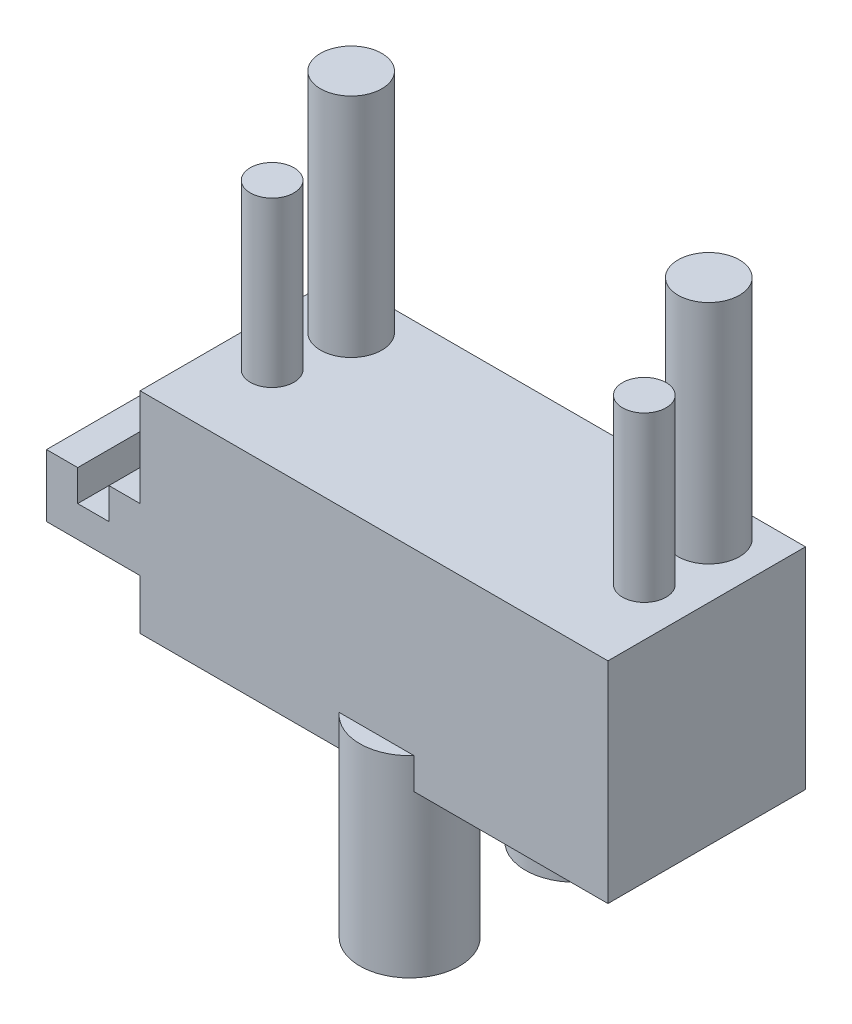
from build123d import *

# Parameters (mm, degrees)
SKETCH1_W                = 22.5
SKETCH1_H                = 7
BOSS_EXTRUDE1_DEPTH      = 1.5
SKETCH2_R                = 1.475
BOSS_EXTRUDE2_DEPTH      = 13.5
SKETCH3_R                = 1.05
BOSS_EXTRUDE3_DEPTH      = 10.5
SKETCH4_W                = 22.5
SKETCH4_H                = 2.5
SKETCH4_H_2              = 7
BOSS_EXTRUDE4_DEPTH      = 6
BOSS_EXTRUDE4_DEPTH_BACK = 1.5
SKETCH8_W                = 22.5
SKETCH8_H                = 9.5
BOSS_EXTRUDE7_DEPTH      = 2.61
SKETCH9_R                = 2.4
BOSS_EXTRUDE8_DEPTH      = 7.76
BOSS_EXTRUDE8_DEPTH_BACK = 1.5
SKETCH15_W               = 9.5
SKETCH15_H               = 3
BOSS_EXTRUDE11_DEPTH     = 4.5
SKETCH16_W               = 1.5
SKETCH16_H               = 9.5
CUT_EXTRUDE3_DEPTH       = 1.5


with BuildPart() as part:
    # Sketch1 → Boss-Extrude1 (new body)
    with BuildSketch(Plane(origin=(0, 0, 0), x_dir=(1, 0, 0), z_dir=(0, 1, 0))):
        with Locations((-28.93578967, -21.079480712)):
            Rectangle(SKETCH1_W, SKETCH1_H)
    extrude(amount=BOSS_EXTRUDE1_DEPTH)

    # Sketch2 → Boss-Extrude2 (add)
    with BuildSketch(Plane(origin=(0, 1.5, 0), x_dir=(1, 0, 0), z_dir=(0, 1, 0))):
        with Locations((-37.53578967, -19.579480712)):
            Circle(SKETCH2_R)
        with Locations((-20.33578967, -19.579480712)):
            Circle(SKETCH2_R)
    extrude(amount=BOSS_EXTRUDE2_DEPTH)

    # Sketch3 → Boss-Extrude3 (add)
    with BuildSketch(Plane(origin=(0, 1.5, 0), x_dir=(1, 0, 0), z_dir=(0, 1, 0))):
        with Locations((-37.88578967, -23.029480712)):
            Circle(SKETCH3_R)
        with Locations((-19.98578967, -23.029480712)):
            Circle(SKETCH3_R)
    extrude(amount=BOSS_EXTRUDE3_DEPTH)

    # Sketch4 → Boss-Extrude4 (add, two sides)
    with BuildSketch(Plane(origin=(0, 0, 0), x_dir=(-1, 0, 0), z_dir=(0, -1, 0))) as boss_extrude4_sk:
        with Locations((28.93578967, -25.829480712)):
            Rectangle(SKETCH4_W, SKETCH4_H)
        with Locations((28.93578967, -21.079480712)):
            Rectangle(SKETCH4_W, SKETCH4_H_2)
    extrude(amount=BOSS_EXTRUDE4_DEPTH)
    extrude(boss_extrude4_sk.sketch, amount=-BOSS_EXTRUDE4_DEPTH_BACK)

    # Sketch8 → Boss-Extrude7 (add)
    with BuildSketch(Plane(origin=(0, 1.5, 0), x_dir=(1, 0, 0), z_dir=(0, 1, 0))):
        with Locations((-28.93578967, -22.329480712)):
            Rectangle(SKETCH8_W, SKETCH8_H)
    extrude(amount=BOSS_EXTRUDE7_DEPTH)

    # Sketch9 → Boss-Extrude8 (add, two sides)
    with BuildSketch(Plane(origin=(0, -6, 0), x_dir=(-1, 0, 0), z_dir=(0, -1, 0))) as boss_extrude8_sk:
        with Locations((28.81078967, -25.489480712)):
            Circle(SKETCH9_R)
        with Locations((28.81078967, -17.519480712)):
            Circle(SKETCH9_R)
    extrude(amount=BOSS_EXTRUDE8_DEPTH)
    extrude(boss_extrude8_sk.sketch, amount=-BOSS_EXTRUDE8_DEPTH_BACK)

    # Sketch15 → Boss-Extrude11 (add)
    with BuildSketch(Plane.ZY.offset(40.18578967)):
        with Locations((22.329480712, -2.09)):
            Rectangle(SKETCH15_W, SKETCH15_H)
    extrude(amount=BOSS_EXTRUDE11_DEPTH)

    # Sketch16 → Cut-Extrude3 (cut)
    with BuildSketch(Plane(origin=(0, -0.59, 0), x_dir=(1, 0, 0), z_dir=(0, 1, 0))):
        with Locations((-42.43578967, -22.329480712)):
            Rectangle(SKETCH16_W, SKETCH16_H)
    extrude(amount=-CUT_EXTRUDE3_DEPTH, mode=Mode.SUBTRACT)


solid = part.part
